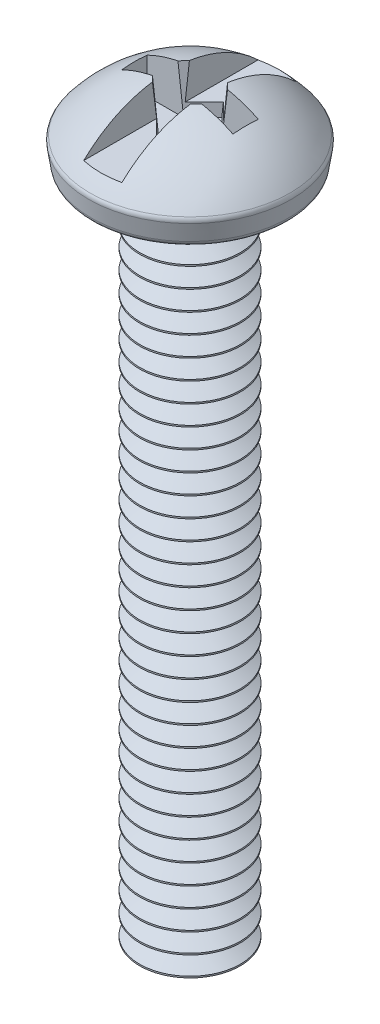
from build123d import *

# Parameters (mm, degrees)
LPATTERN1_COUNT         = 34
LPATTERN1_PITCH         = 0.79375
SKETCH3_W               = 1.524
SKETCH3_H               = 2.54
CUT_EXTRUDE1_DEPTH      = 5.050810207
CUT_EXTRUDE1_DEPTH_BACK = 5.050810207
SKETCH4_W               = 4.445
SKETCH4_H               = 1.016
CUT_EXTRUDE2_DEPTH      = 2.403024863
CUT_EXTRUDE2_DEPTH_BACK = 0.508
CUT_EXTRUDE3_DEPTH      = 2.885268156
CUT_EXTRUDE3_TAPER      = -5


with BuildPart() as part:
    # Sketch1 → Revolve1 (revolve)
    with BuildSketch(Plane.XY):
        with BuildLine():
            Line((0, 3.048), (0, -26.9875))
            Line((0, -26.9875), (2.0066, -26.9875))
            Line((2.0066, -26.9875), (2.0066, 0))
            Line((2.0066, 0), (3.692858395, 0))
            ThreePointArc((3.692858395, 0), (3.858607705, 0.061533987), (3.944048229, 0.216321525))
            Line((3.944048229, 0.216321525), (4.047999941, 0.90933294))
            ThreePointArc((4.047999941, 0.90933294), (4.042390446, 1.011867387), (3.996642218, 1.103801489))
            ThreePointArc((3.996642218, 1.103801489), (2.22222056, 2.536165472), (0, 3.048))
        make_face()
    revolve(axis=Axis((0, 3.048, 0), (0, -1, 0)))

    # Sketch2 → Cut-Revolve1 (revolve, cut)
    with BuildSketch(Plane.XY):
        Polygon((2.852757664, -26.590625), (2.852757664, -27.384375), (2.059007664, -27.384375), (1.3716, -26.9875), (2.059007664, -26.590625), align=None)
    cut_revolve1 = revolve(axis=Axis((0, 0, 0), (0, -1, 0)), mode=Mode.SUBTRACT)

    # LPattern1: Cut-Revolve1 ×34
    with Locations(*[(0, i * LPATTERN1_PITCH, 0) for i in range(1, LPATTERN1_COUNT)]):
        add(cut_revolve1, mode=Mode.SUBTRACT)

    # Sketch3 → Cut-Extrude1 (cut, two sides)
    with BuildSketch(Plane.XY) as cut_extrude1_sk:
        with Locations((0, 2.8575)):
            Rectangle(SKETCH3_W, SKETCH3_H)
    extrude(amount=CUT_EXTRUDE1_DEPTH, mode=Mode.SUBTRACT)
    extrude(cut_extrude1_sk.sketch, amount=-CUT_EXTRUDE1_DEPTH_BACK, mode=Mode.SUBTRACT)

    # Sketch4 → Cut-Extrude2 (cut, two sides)
    with BuildSketch(Plane(origin=(0, 1.5875, 0), x_dir=(1, 0, 0), z_dir=(0, 1, 0))) as cut_extrude2_sk:
        Rectangle(SKETCH4_W, SKETCH4_H)
    extrude(amount=CUT_EXTRUDE2_DEPTH, mode=Mode.SUBTRACT)
    extrude(cut_extrude2_sk.sketch, amount=-CUT_EXTRUDE2_DEPTH_BACK, mode=Mode.SUBTRACT)

    # Sketch5 → Cut-Extrude3 (cut, through all)
    with BuildSketch(Plane(origin=(0, 1.0795, 0), x_dir=(1, 0, 0), z_dir=(0, 1, 0))):
        Polygon((0, -1.27), (1.27, 0), (0, 1.27), (-1.27, 0), align=None)
    extrude(amount=CUT_EXTRUDE3_DEPTH, taper=CUT_EXTRUDE3_TAPER, mode=Mode.SUBTRACT)


solid = part.part
